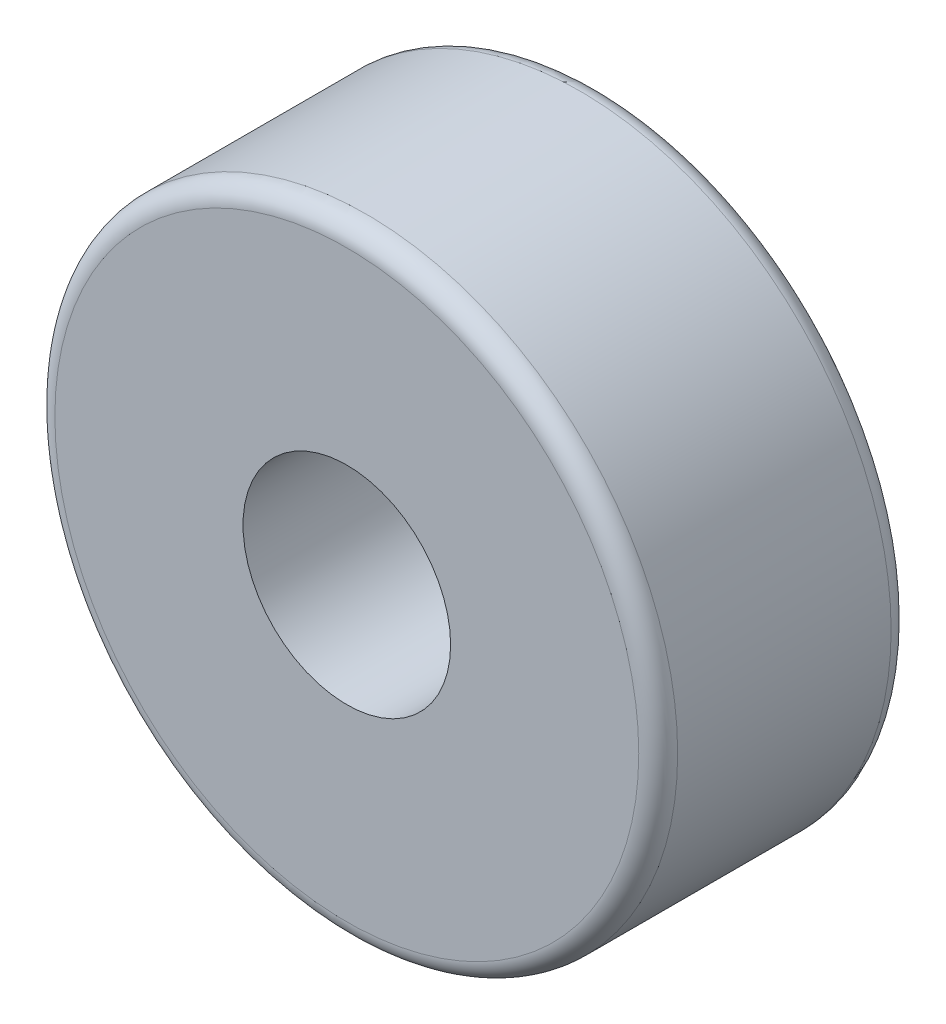
from build123d import *

# Parameters (mm, degrees)
SKETCH1_R           = 38.1
SKETCH1_R_2         = 12.7
EXTRUDE_THIN1_DEPTH = 30.876912538
FILLET1_R           = 2.38


with BuildPart() as part:
    # Sketch1 → Extrude-Thin1 (new body)
    with BuildSketch(Plane.XY):
        Circle(SKETCH1_R)
        Circle(SKETCH1_R_2, mode=Mode.SUBTRACT)
    extrude(amount=EXTRUDE_THIN1_DEPTH)

    # Fillet1
    fillet1_edges = [part.edges().sort_by_distance(p)[0] for p in [
        (-38.1, 0, 0),
        (-38.1, 0, 30.876912538),
    ]]
    fillet(fillet1_edges, radius=FILLET1_R)


solid = part.part
